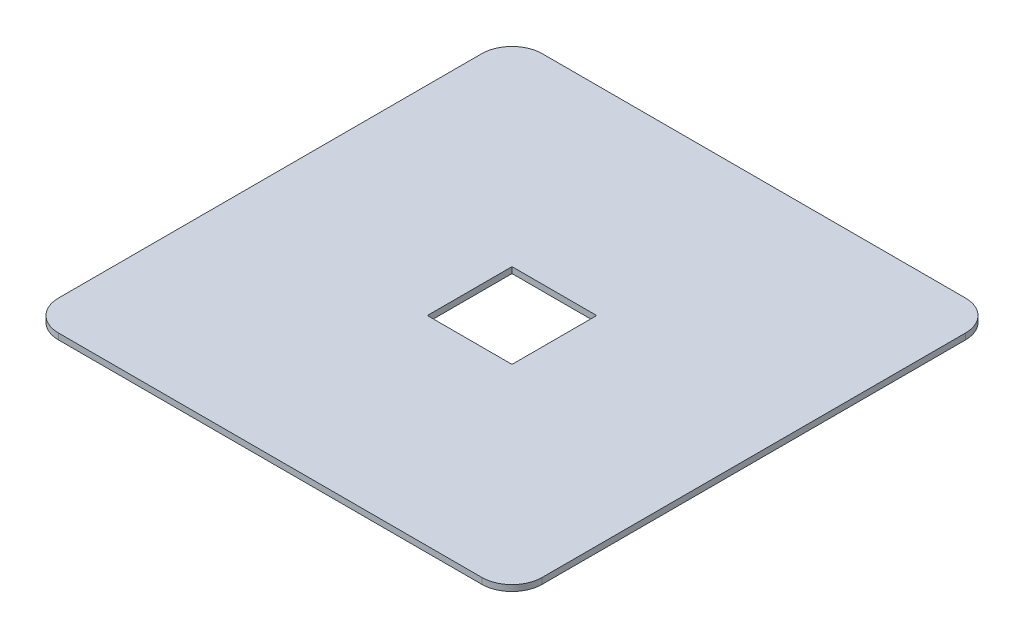
from build123d import *

# Parameters (mm, degrees)
ESQUISSE1_W             = 80
ESQUISSE1_H             = 80
EXTRUSION1_DEPTH        = 1
CONG_1_R                = 5
ESQUISSE2_W             = 14
ESQUISSE2_H             = 14
ENL_V_MAT_EXTRU_1_DEPTH = 2


with BuildPart() as part:
    # Esquisse1 → Extrusion1 (new body)
    with BuildSketch(Plane(origin=(0, 0, 0), x_dir=(1, 0, 0), z_dir=(0, 1, 0))):
        with Locations((40, 40)):
            Rectangle(ESQUISSE1_W, ESQUISSE1_H)
    extrude(amount=EXTRUSION1_DEPTH)

    # Congé1
    cong_1_edges = [part.edges().sort_by_distance(p)[0] for p in [
        (0, 0.5, -80),
        (80, 0.5, -80),
        (80, 0.5, 0),
        (0, 0.5, 0),
    ]]
    fillet(cong_1_edges, radius=CONG_1_R)

    # Esquisse2 → Enlèv. mat.-Extru.1 (cut, through all)
    with BuildSketch(Plane(origin=(0, 1, 0), x_dir=(1, 0, 0), z_dir=(0, 1, 0))):
        with Locations((40, 40)):
            Rectangle(ESQUISSE2_W, ESQUISSE2_H)
    extrude(amount=-ENL_V_MAT_EXTRU_1_DEPTH, mode=Mode.SUBTRACT)


solid = part.part
